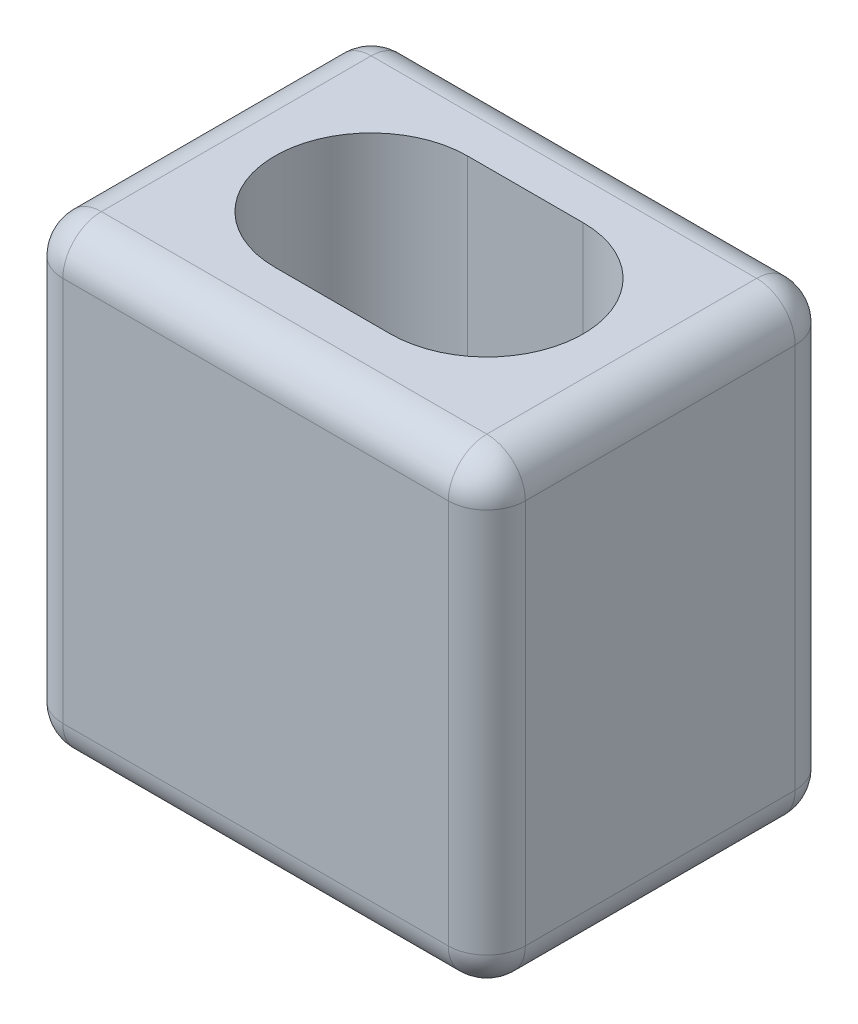
from build123d import *

# Parameters (mm, degrees)
SKETCH1_W           = 152.4
SKETCH1_H           = 114.3
BOSS_EXTRUDE1_DEPTH = 152.4
FILLET1_R           = 12.7


with BuildPart() as part:
    # Sketch1 → Boss-Extrude1 (new body)
    with BuildSketch(Plane(origin=(0, 0, 0), x_dir=(1, 0, 0), z_dir=(0, 1, 0))):
        Rectangle(SKETCH1_W, SKETCH1_H)
        with BuildLine():
            Line((-19.05, 31.75), (19.05, 31.75))
            ThreePointArc((19.05, 31.75), (50.8, 0), (19.05, -31.75))
            Line((19.05, -31.75), (-19.05, -31.75))
            ThreePointArc((-19.05, -31.75), (-50.8, 0), (-19.05, 31.75))
        make_face(mode=Mode.SUBTRACT)
    extrude(amount=BOSS_EXTRUDE1_DEPTH)

    # Fillet1
    fillet1_edges = [part.edges().sort_by_distance(p)[0] for p in [
        (-76.2, 152.4, 0),
        (0, 152.4, 57.15),
        (76.2, 152.4, 0),
        (0, 0, 57.15),
        (-76.2, 0, 0),
        (0, 0, -57.15),
        (76.2, 0, 0),
        (76.2, 76.2, 57.15),
        (-76.2, 76.2, 57.15),
        (-76.2, 76.2, -57.15),
        (76.2, 76.2, -57.15),
        (0, 152.4, -57.15),
    ]]
    fillet(fillet1_edges, radius=FILLET1_R)


solid = part.part
